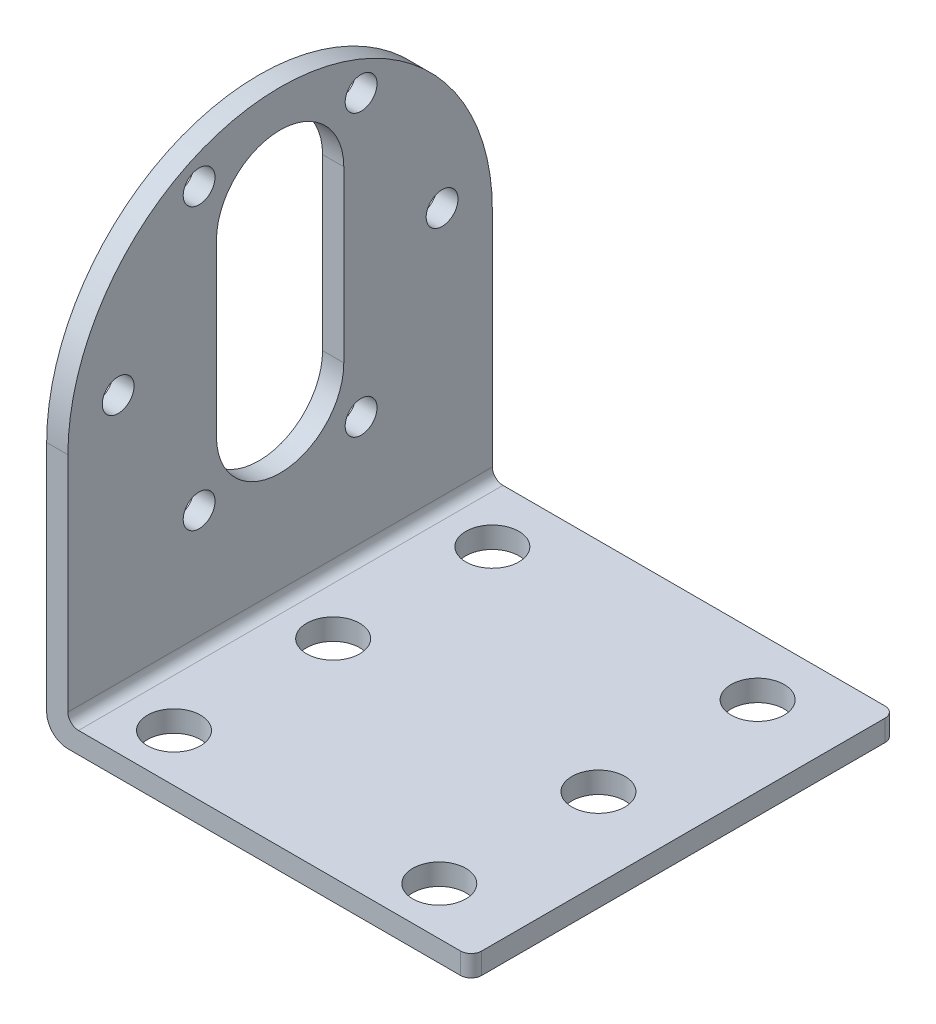
from build123d import *

# Parameters (mm, degrees)
BOSS_EXTRUDE1_DEPTH = 40
HOLE1_D             = 5
CUT_EXTRUDE1_DEPTH  = 40
CUT_EXTRUDE2_DEPTH  = 40
SKETCH7_R           = 1.5
CUT_EXTRUDE3_DEPTH  = 40
FILLET1_R           = 1
SKETCH10_R          = 2.5
CUT_EXTRUDE4_DEPTH  = 40


with BuildPart() as part:
    # Sketch2 → Boss-Extrude1 (new body)
    with BuildSketch(Plane.XY):
        with BuildLine():
            Line((2, 0), (40, 0))
            Line((40, 0), (40, 2))
            Line((40, 2), (3, 2))
            ThreePointArc((3, 2), (2.292893219, 2.292893219), (2, 3))
            Line((2, 3), (2, 45))
            Line((2, 45), (0, 45))
            Line((0, 45), (0, 2))
            ThreePointArc((0, 2), (0.585786438, 0.585786438), (2, 0))
        make_face()
    extrude(amount=BOSS_EXTRUDE1_DEPTH)

    # Hole1 (through all)
    with Locations(Plane(origin=(0, 2, 0), x_dir=(1, 0, 0), z_dir=(0, 1, 0))):
        with Locations((32.5, -35.5), (32.5, -5.5), (7.5, -5.5), (7.5, -35.5)):
            Hole(HOLE1_D / 2)

    # Sketch5 → Cut-Extrude1 (cut)
    with BuildSketch(Plane(origin=(2, 0, 0), x_dir=(0, 0, -1), z_dir=(1, 0, 0))):
        with BuildLine():
            Line((-40, 45), (-40, 24))
            ThreePointArc((-40, 24), (-20, 44), (0, 24))
            Line((0, 24), (0, 45))
            Line((0, 45), (-40, 45))
        make_face()
    extrude(amount=-CUT_EXTRUDE1_DEPTH, mode=Mode.SUBTRACT)

    # Sketch6 → Cut-Extrude2 (cut)
    with BuildSketch(Plane(origin=(2, 0, 0), x_dir=(0, 0, -1), z_dir=(1, 0, 0))):
        with BuildLine():
            Line((-14, 34.5), (-14, 18.5))
            ThreePointArc((-14, 18.5), (-20, 12.5), (-26, 18.5))
            Line((-26, 18.5), (-26, 34.5))
            ThreePointArc((-26, 34.5), (-20, 40.5), (-14, 34.5))
        make_face()
    extrude(amount=-CUT_EXTRUDE2_DEPTH, mode=Mode.SUBTRACT)

    # Sketch7 → Cut-Extrude3 (cut)
    with BuildSketch(Plane(origin=(2, 0, 0), x_dir=(0, 0, -1), z_dir=(1, 0, 0))):
        with Locations((-4.735, 26.5)):
            Circle(SKETCH7_R)
        with Locations((-35.265, 26.5)):
            Circle(SKETCH7_R)
        with Locations((-27.6325, 13.280122211)):
            Circle(SKETCH7_R)
        with Locations((-12.3675, 13.280122211)):
            Circle(SKETCH7_R)
        with Locations((-27.6325, 39.719877789)):
            Circle(SKETCH7_R)
        with Locations((-12.3675, 39.719877789)):
            Circle(SKETCH7_R)
    extrude(amount=-CUT_EXTRUDE3_DEPTH, mode=Mode.SUBTRACT)

    # Fillet1
    fillet1_edges = [part.edges().sort_by_distance(p)[0] for p in [
        (40, 1, 0),
        (40, 1, 40),
    ]]
    fillet(fillet1_edges, radius=FILLET1_R)

    # Sketch10 → Cut-Extrude4 (cut)
    with BuildSketch(Plane(origin=(0, 2, 0), x_dir=(1, 0, 0), z_dir=(0, 1, 0))):
        with Locations((7.5, -20.5)):
            Circle(SKETCH10_R)
        with Locations((32.5, -20.5)):
            Circle(SKETCH10_R)
    extrude(amount=-CUT_EXTRUDE4_DEPTH, mode=Mode.SUBTRACT)


solid = part.part
